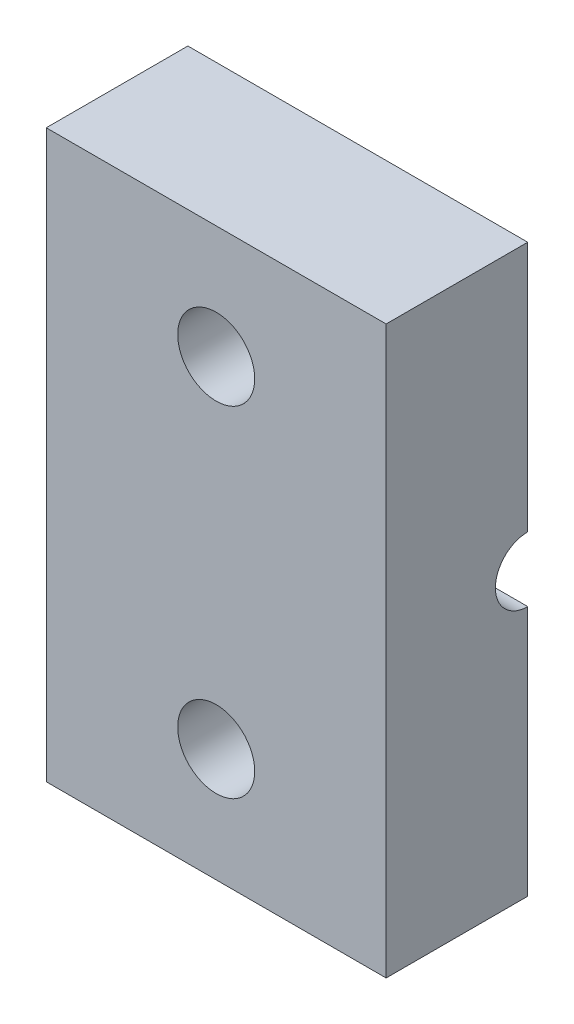
from build123d import *

# Parameters (mm, degrees)
SKETCH1_W                   = 15.24
SKETCH1_H                   = 25.4
BOSS_EXTRUDE1_DEPTH         = 6.35
F_29_0_136_DIAMETER_HOLE1_D = 3.4544
SKETCH6_R                   = 1.45
CUT_EXTRUDE1_DEPTH          = 16.24


with BuildPart() as part:
    # Sketch1 → Boss-Extrude1 (new body)
    with BuildSketch(Plane.XY):
        Rectangle(SKETCH1_W, SKETCH1_H)
    extrude(amount=BOSS_EXTRUDE1_DEPTH)

    # #29 (0.136) Diameter Hole1 (through all)
    with Locations(Plane.XY.offset(6.35)):
        with Locations((0, -7.62), (0, 7.62)):
            Hole(F_29_0_136_DIAMETER_HOLE1_D / 2)

    # Sketch6 → Cut-Extrude1 (cut, through all)
    with BuildSketch(Plane.ZY.offset(7.62)):
        Circle(SKETCH6_R)
    extrude(amount=-CUT_EXTRUDE1_DEPTH, mode=Mode.SUBTRACT)


solid = part.part
